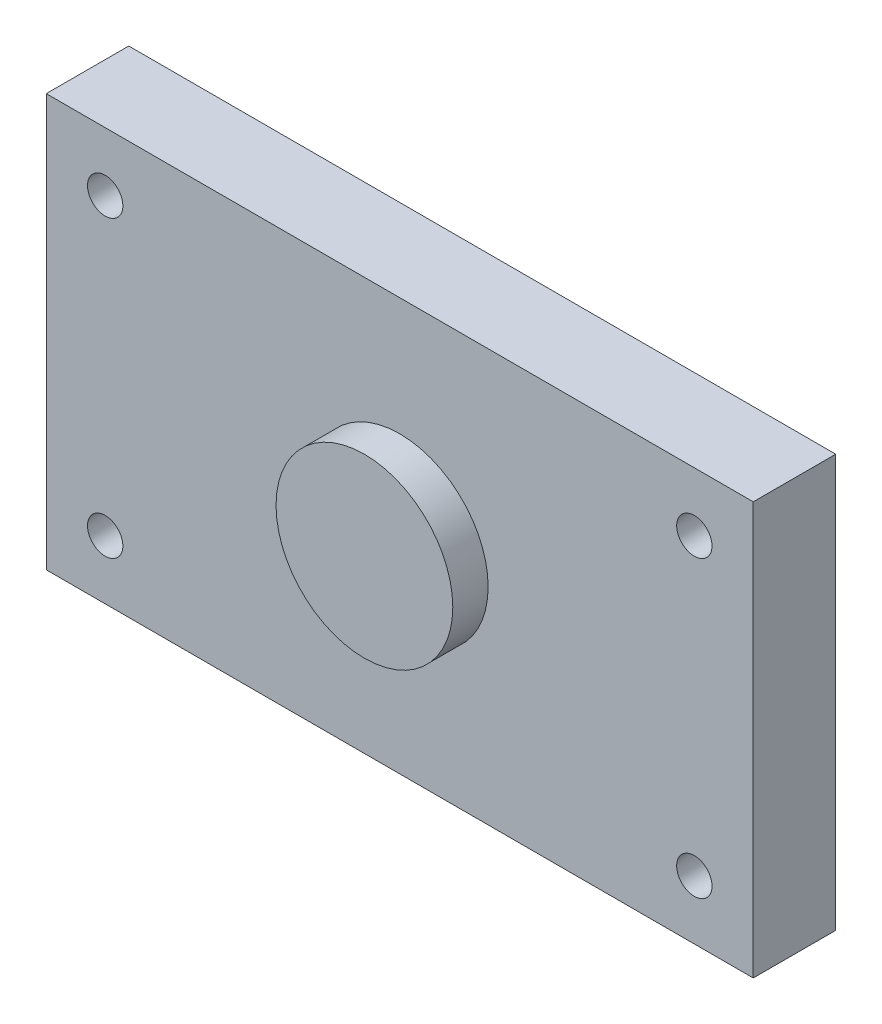
from build123d import *

# Parameters (mm, degrees)
SKETCH1_R               = 1.5
BOSS_EXTRUDE1_DEPTH     = 7
SKETCH5_R               = 7.5
BOSS_EXTRUDE5_DEPTH     = 3
CUT_EXTRUDE1_DEPTH      = 3
CUT_EXTRUDE1_DEPTH_BACK = 3
SKETCH1_3_R             = 4


with BuildPart() as part:
    # Sketch1 → Boss-Extrude1 (new body)
    with BuildSketch(Plane.XY):
        Polygon((-32.5, 17.5), (-92.5, 17.5), (-92.5, 0), (-92.5, -17.5), (-32.5, -17.5), align=None)
        with Locations((-87.5, -12.5)):
            Circle(SKETCH1_R, mode=Mode.SUBTRACT)
        with Locations((-37.5, -12.5)):
            Circle(SKETCH1_R, mode=Mode.SUBTRACT)
        with Locations((-87.5, 12.5)):
            Circle(SKETCH1_R, mode=Mode.SUBTRACT)
        with Locations((-37.5, 12.5)):
            Circle(SKETCH1_R, mode=Mode.SUBTRACT)
    extrude(amount=BOSS_EXTRUDE1_DEPTH)

    # Sketch5 → Boss-Extrude5 (add)
    with BuildSketch(Plane.XY.offset(7)):
        with Locations((-62.5, 0)):
            Circle(SKETCH5_R)
    extrude(amount=BOSS_EXTRUDE5_DEPTH)

    # Sketch1_3 → Cut-Extrude1 (cut, two sides: drawn at the far end of the back side and taken through both)
    with BuildSketch(Plane.XY.offset(-CUT_EXTRUDE1_DEPTH_BACK)):
        with Locations((-62.5, 0)):
            Circle(SKETCH1_3_R)
    extrude(amount=CUT_EXTRUDE1_DEPTH + CUT_EXTRUDE1_DEPTH_BACK, mode=Mode.SUBTRACT)


solid = part.part
